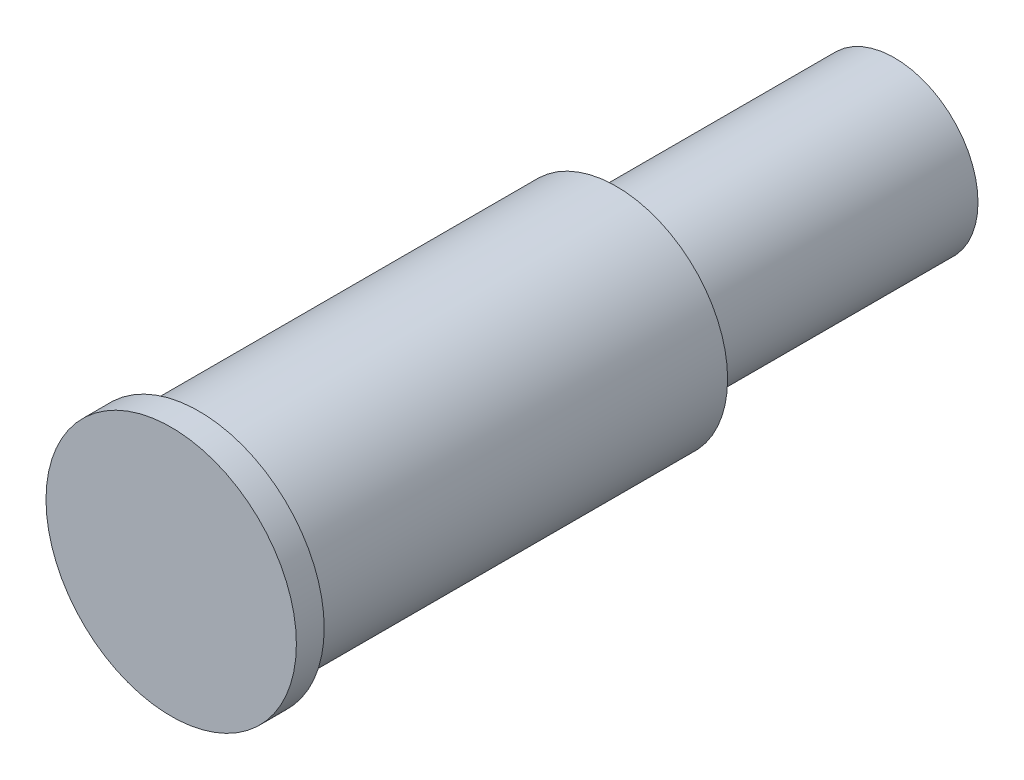
from build123d import *

# Parameters (mm, degrees)
SKETCH_1_R      = 3
EXTRUDE_1_DEPTH = 10
SKETCH_2_R      = 4
EXTRUDE_2_DEPTH = 15
SKETCH_3_R      = 4.5
EXTRUDE_3_DEPTH = 1


with BuildPart() as part:
    # 草图1 → 凸台-拉伸1 (new body)
    with BuildSketch(Plane.XY):
        Circle(SKETCH_1_R)
    extrude(amount=EXTRUDE_1_DEPTH)

    # 草图2 → 凸台-拉伸2 (add)
    with BuildSketch(Plane.XY.offset(10)):
        Circle(SKETCH_2_R)
    extrude(amount=EXTRUDE_2_DEPTH)

    # 草图3 → 凸台-拉伸3 (add)
    with BuildSketch(Plane.XY.offset(25)):
        Circle(SKETCH_3_R)
    extrude(amount=EXTRUDE_3_DEPTH)


solid = part.part
